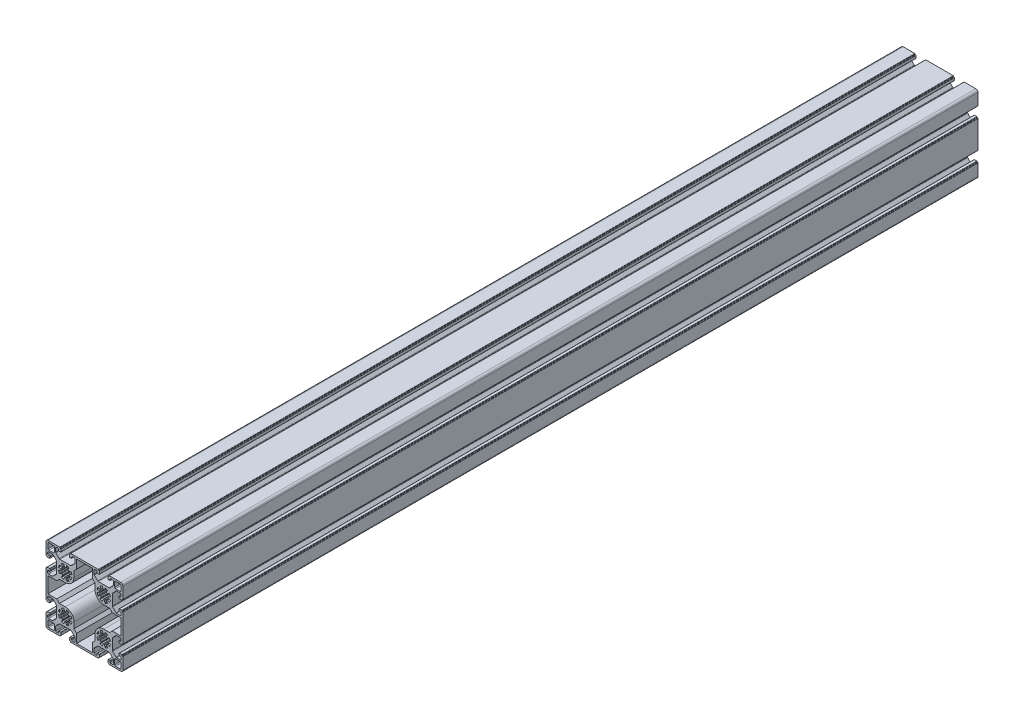
from build123d import *

# Parameters (mm, degrees)
EXTRUDE_1_DEPTH = 1000


with BuildPart() as part:
    # Эскиз1 → Бобышка-Вытянуть1 (new body)
    with BuildSketch(Plane.XY):
        with BuildLine():
            Line((-22.5, 11.25), (-22.5, 20))
            ThreePointArc((-22.5, 20), (-21.767766953, 21.767766953), (-20, 22.5))
            Line((-20, 22.5), (-11.25, 22.5))
            Line((-11.25, 22.5), (-6.4, 22.5))
            ThreePointArc((-6.4, 22.5), (-6.187867966, 22.412132034), (-6.1, 22.2))
            Line((-6.1, 22.2), (-6.1, 21.8))
            ThreePointArc((-6.1, 21.8), (-6.012132034, 21.587867966), (-5.8, 21.5))
            Line((-5.8, 21.5), (-5.4, 21.5))
            ThreePointArc((-5.4, 21.5), (-5.187867966, 21.412132034), (-5.1, 21.2))
            Line((-5.1, 21.2), (-5.1, 18.3))
            ThreePointArc((-5.1, 18.3), (-5.187867966, 18.087867966), (-5.4, 18))
            Line((-5.4, 18), (-7.3, 18))
            ThreePointArc((-7.3, 18), (-7.512132034, 18.087867966), (-7.6, 18.3))
            Line((-7.6, 18.3), (-7.6, 19.5))
            ThreePointArc((-7.6, 19.5), (-7.892893219, 20.207106781), (-8.6, 20.5))
            Line((-8.6, 20.5), (-10.25, 20.5))
            ThreePointArc((-10.25, 20.5), (-10.957106781, 20.207106781), (-11.25, 19.5))
            Line((-11.25, 19.5), (-11.25, 15.114213562))
            ThreePointArc((-11.25, 15.114213562), (-11.173879533, 14.73153013), (-10.957106781, 14.407106781))
            Line((-10.957106781, 14.407106781), (-7.042893219, 10.492893219))
            ThreePointArc((-7.042893219, 10.492893219), (-6.71846987, 10.276120467), (-6.335786438, 10.2))
            Line((-6.335786438, 10.2), (6.335786438, 10.2))
            ThreePointArc((6.335786438, 10.2), (6.71846987, 10.276120467), (7.042893219, 10.492893219))
            Line((7.042893219, 10.492893219), (10.957106781, 14.407106781))
            ThreePointArc((10.957106781, 14.407106781), (11.173879533, 14.73153013), (11.25, 15.114213562))
            Line((11.25, 15.114213562), (11.25, 19.5))
            ThreePointArc((11.25, 19.5), (10.957106781, 20.207106781), (10.25, 20.5))
            Line((10.25, 20.5), (8.6, 20.5))
            ThreePointArc((8.6, 20.5), (7.892893219, 20.207106781), (7.6, 19.5))
            Line((7.6, 19.5), (7.6, 18.3))
            ThreePointArc((7.6, 18.3), (7.512132034, 18.087867966), (7.3, 18))
            Line((7.3, 18), (5.4, 18))
            ThreePointArc((5.4, 18), (5.187867966, 18.087867966), (5.1, 18.3))
            Line((5.1, 18.3), (5.1, 21.2))
            ThreePointArc((5.1, 21.2), (5.187867966, 21.412132034), (5.4, 21.5))
            Line((5.4, 21.5), (5.8, 21.5))
            ThreePointArc((5.8, 21.5), (6.012132034, 21.587867966), (6.1, 21.8))
            Line((6.1, 21.8), (6.1, 22.2))
            ThreePointArc((6.1, 22.2), (6.187867966, 22.412132034), (6.4, 22.5))
            Line((6.4, 22.5), (11.25, 22.5))
            Line((11.25, 22.5), (33.75, 22.5))
            Line((33.75, 22.5), (38.6, 22.5))
            ThreePointArc((38.6, 22.5), (38.812132034, 22.412132034), (38.9, 22.2))
            Line((38.9, 22.2), (38.9, 21.8))
            ThreePointArc((38.9, 21.8), (38.987867966, 21.587867966), (39.2, 21.5))
            Line((39.2, 21.5), (39.6, 21.5))
            ThreePointArc((39.6, 21.5), (39.812132034, 21.412132034), (39.9, 21.2))
            Line((39.9, 21.2), (39.9, 18.3))
            ThreePointArc((39.9, 18.3), (39.812132034, 18.087867966), (39.6, 18))
            Line((39.6, 18), (37.7, 18))
            ThreePointArc((37.7, 18), (37.487867966, 18.087867966), (37.4, 18.3))
            Line((37.4, 18.3), (37.4, 19.5))
            ThreePointArc((37.4, 19.5), (37.107106781, 20.207106781), (36.4, 20.5))
            Line((36.4, 20.5), (34.75, 20.5))
            ThreePointArc((34.75, 20.5), (34.042893219, 20.207106781), (33.75, 19.5))
            Line((33.75, 19.5), (33.75, 15.114213562))
            ThreePointArc((33.75, 15.114213562), (33.826120467, 14.73153013), (34.042893219, 14.407106781))
            Line((34.042893219, 14.407106781), (37.957106781, 10.492893219))
            ThreePointArc((37.957106781, 10.492893219), (38.28153013, 10.276120467), (38.664213562, 10.2))
            Line((38.664213562, 10.2), (51.335786438, 10.2))
            ThreePointArc((51.335786438, 10.2), (51.71846987, 10.276120467), (52.042893219, 10.492893219))
            Line((52.042893219, 10.492893219), (55.957106781, 14.407106781))
            ThreePointArc((55.957106781, 14.407106781), (56.173879533, 14.73153013), (56.25, 15.114213562))
            Line((56.25, 15.114213562), (56.25, 19.5))
            ThreePointArc((56.25, 19.5), (55.957106781, 20.207106781), (55.25, 20.5))
            Line((55.25, 20.5), (53.6, 20.5))
            ThreePointArc((53.6, 20.5), (52.892893219, 20.207106781), (52.6, 19.5))
            Line((52.6, 19.5), (52.6, 18.3))
            ThreePointArc((52.6, 18.3), (52.512132034, 18.087867966), (52.3, 18))
            Line((52.3, 18), (50.4, 18))
            ThreePointArc((50.4, 18), (50.187867966, 18.087867966), (50.1, 18.3))
            Line((50.1, 18.3), (50.1, 21.2))
            ThreePointArc((50.1, 21.2), (50.187867966, 21.412132034), (50.4, 21.5))
            Line((50.4, 21.5), (50.8, 21.5))
            ThreePointArc((50.8, 21.5), (51.012132034, 21.587867966), (51.1, 21.8))
            Line((51.1, 21.8), (51.1, 22.2))
            ThreePointArc((51.1, 22.2), (51.187867966, 22.412132034), (51.4, 22.5))
            Line((51.4, 22.5), (56.25, 22.5))
            Line((56.25, 22.5), (65, 22.5))
            ThreePointArc((65, 22.5), (66.767766953, 21.767766953), (67.5, 20))
            Line((67.5, 20), (67.5, 11.25))
            Line((67.5, 11.25), (67.5, 6.4))
            ThreePointArc((67.5, 6.4), (67.412132034, 6.187867966), (67.2, 6.1))
            Line((67.2, 6.1), (66.8, 6.1))
            ThreePointArc((66.8, 6.1), (66.587867966, 6.012132034), (66.5, 5.8))
            Line((66.5, 5.8), (66.5, 5.4))
            ThreePointArc((66.5, 5.4), (66.412132034, 5.187867966), (66.2, 5.1))
            Line((66.2, 5.1), (63.3, 5.1))
            ThreePointArc((63.3, 5.1), (63.087867966, 5.187867966), (63, 5.4))
            Line((63, 5.4), (63, 7.3))
            ThreePointArc((63, 7.3), (63.087867966, 7.512132034), (63.3, 7.6))
            Line((63.3, 7.6), (64.5, 7.6))
            ThreePointArc((64.5, 7.6), (65.207106781, 7.892893219), (65.5, 8.6))
            Line((65.5, 8.6), (65.5, 10.25))
            ThreePointArc((65.5, 10.25), (65.207106781, 10.957106781), (64.5, 11.25))
            Line((64.5, 11.25), (60.114213562, 11.25))
            ThreePointArc((60.114213562, 11.25), (59.73153013, 11.173879533), (59.407106781, 10.957106781))
            Line((59.407106781, 10.957106781), (55.492893219, 7.042893219))
            ThreePointArc((55.492893219, 7.042893219), (55.276120467, 6.71846987), (55.2, 6.335786438))
            Line((55.2, 6.335786438), (55.2, -6.335786438))
            ThreePointArc((55.2, -6.335786438), (55.276120467, -6.71846987), (55.492893219, -7.042893219))
            Line((55.492893219, -7.042893219), (59.407106781, -10.957106781))
            ThreePointArc((59.407106781, -10.957106781), (59.73153013, -11.173879533), (60.114213562, -11.25))
            Line((60.114213562, -11.25), (64.5, -11.25))
            ThreePointArc((64.5, -11.25), (65.207106781, -10.957106781), (65.5, -10.25))
            Line((65.5, -10.25), (65.5, -8.6))
            ThreePointArc((65.5, -8.6), (65.207106781, -7.892893219), (64.5, -7.6))
            Line((64.5, -7.6), (63.3, -7.6))
            ThreePointArc((63.3, -7.6), (63.087867966, -7.512132034), (63, -7.3))
            Line((63, -7.3), (63, -5.4))
            ThreePointArc((63, -5.4), (63.087867966, -5.187867966), (63.3, -5.1))
            Line((63.3, -5.1), (66.2, -5.1))
            ThreePointArc((66.2, -5.1), (66.412132034, -5.187867966), (66.5, -5.4))
            Line((66.5, -5.4), (66.5, -5.8))
            ThreePointArc((66.5, -5.8), (66.587867966, -6.012132034), (66.8, -6.1))
            Line((66.8, -6.1), (67.2, -6.1))
            ThreePointArc((67.2, -6.1), (67.412132034, -6.187867966), (67.5, -6.4))
            Line((67.5, -6.4), (67.5, -11.25))
            Line((67.5, -11.25), (67.5, -33.75))
            Line((67.5, -33.75), (67.5, -38.6))
            ThreePointArc((67.5, -38.6), (67.412132034, -38.812132034), (67.2, -38.9))
            Line((67.2, -38.9), (66.8, -38.9))
            ThreePointArc((66.8, -38.9), (66.587867966, -38.987867966), (66.5, -39.2))
            Line((66.5, -39.2), (66.5, -39.6))
            ThreePointArc((66.5, -39.6), (66.412132034, -39.812132034), (66.2, -39.9))
            Line((66.2, -39.9), (63.3, -39.9))
            ThreePointArc((63.3, -39.9), (63.087867966, -39.812132034), (63, -39.6))
            Line((63, -39.6), (63, -37.7))
            ThreePointArc((63, -37.7), (63.087867966, -37.487867966), (63.3, -37.4))
            Line((63.3, -37.4), (64.5, -37.4))
            ThreePointArc((64.5, -37.4), (65.207106781, -37.107106781), (65.5, -36.4))
            Line((65.5, -36.4), (65.5, -34.75))
            ThreePointArc((65.5, -34.75), (65.207106781, -34.042893219), (64.5, -33.75))
            Line((64.5, -33.75), (60.114213562, -33.75))
            ThreePointArc((60.114213562, -33.75), (59.73153013, -33.826120467), (59.407106781, -34.042893219))
            Line((59.407106781, -34.042893219), (55.492893219, -37.957106781))
            ThreePointArc((55.492893219, -37.957106781), (55.276120467, -38.28153013), (55.2, -38.664213562))
            Line((55.2, -38.664213562), (55.2, -51.335786438))
            ThreePointArc((55.2, -51.335786438), (55.276120467, -51.71846987), (55.492893219, -52.042893219))
            Line((55.492893219, -52.042893219), (59.407106781, -55.957106781))
            ThreePointArc((59.407106781, -55.957106781), (59.73153013, -56.173879533), (60.114213562, -56.25))
            Line((60.114213562, -56.25), (64.5, -56.25))
            ThreePointArc((64.5, -56.25), (65.207106781, -55.957106781), (65.5, -55.25))
            Line((65.5, -55.25), (65.5, -53.6))
            ThreePointArc((65.5, -53.6), (65.207106781, -52.892893219), (64.5, -52.6))
            Line((64.5, -52.6), (63.3, -52.6))
            ThreePointArc((63.3, -52.6), (63.087867966, -52.512132034), (63, -52.3))
            Line((63, -52.3), (63, -50.4))
            ThreePointArc((63, -50.4), (63.087867966, -50.187867966), (63.3, -50.1))
            Line((63.3, -50.1), (66.2, -50.1))
            ThreePointArc((66.2, -50.1), (66.412132034, -50.187867966), (66.5, -50.4))
            Line((66.5, -50.4), (66.5, -50.8))
            ThreePointArc((66.5, -50.8), (66.587867966, -51.012132034), (66.8, -51.1))
            Line((66.8, -51.1), (67.2, -51.1))
            ThreePointArc((67.2, -51.1), (67.412132034, -51.187867966), (67.5, -51.4))
            Line((67.5, -51.4), (67.5, -56.25))
            Line((67.5, -56.25), (67.5, -65))
            ThreePointArc((67.5, -65), (66.767766953, -66.767766953), (65, -67.5))
            Line((65, -67.5), (56.25, -67.5))
            Line((56.25, -67.5), (51.4, -67.5))
            ThreePointArc((51.4, -67.5), (51.187867966, -67.412132034), (51.1, -67.2))
            Line((51.1, -67.2), (51.1, -66.8))
            ThreePointArc((51.1, -66.8), (51.012132034, -66.587867966), (50.8, -66.5))
            Line((50.8, -66.5), (50.4, -66.5))
            ThreePointArc((50.4, -66.5), (50.187867966, -66.412132034), (50.1, -66.2))
            Line((50.1, -66.2), (50.1, -63.3))
            ThreePointArc((50.1, -63.3), (50.187867966, -63.087867966), (50.4, -63))
            Line((50.4, -63), (52.3, -63))
            ThreePointArc((52.3, -63), (52.512132034, -63.087867966), (52.6, -63.3))
            Line((52.6, -63.3), (52.6, -64.5))
            ThreePointArc((52.6, -64.5), (52.892893219, -65.207106781), (53.6, -65.5))
            Line((53.6, -65.5), (55.25, -65.5))
            ThreePointArc((55.25, -65.5), (55.957106781, -65.207106781), (56.25, -64.5))
            Line((56.25, -64.5), (56.25, -60.114213562))
            ThreePointArc((56.25, -60.114213562), (56.173879533, -59.73153013), (55.957106781, -59.407106781))
            Line((55.957106781, -59.407106781), (52.042893219, -55.492893219))
            ThreePointArc((52.042893219, -55.492893219), (51.71846987, -55.276120467), (51.335786438, -55.2))
            Line((51.335786438, -55.2), (38.664213562, -55.2))
            ThreePointArc((38.664213562, -55.2), (38.28153013, -55.276120467), (37.957106781, -55.492893219))
            Line((37.957106781, -55.492893219), (34.042893219, -59.407106781))
            ThreePointArc((34.042893219, -59.407106781), (33.826120467, -59.73153013), (33.75, -60.114213562))
            Line((33.75, -60.114213562), (33.75, -64.5))
            ThreePointArc((33.75, -64.5), (34.042893219, -65.207106781), (34.75, -65.5))
            Line((34.75, -65.5), (36.4, -65.5))
            ThreePointArc((36.4, -65.5), (37.107106781, -65.207106781), (37.4, -64.5))
            Line((37.4, -64.5), (37.4, -63.3))
            ThreePointArc((37.4, -63.3), (37.487867966, -63.087867966), (37.7, -63))
            Line((37.7, -63), (39.6, -63))
            ThreePointArc((39.6, -63), (39.812132034, -63.087867966), (39.9, -63.3))
            Line((39.9, -63.3), (39.9, -66.2))
            ThreePointArc((39.9, -66.2), (39.812132034, -66.412132034), (39.6, -66.5))
            Line((39.6, -66.5), (39.2, -66.5))
            ThreePointArc((39.2, -66.5), (38.987867966, -66.587867966), (38.9, -66.8))
            Line((38.9, -66.8), (38.9, -67.2))
            ThreePointArc((38.9, -67.2), (38.812132034, -67.412132034), (38.6, -67.5))
            Line((38.6, -67.5), (33.75, -67.5))
            Line((33.75, -67.5), (11.25, -67.5))
            Line((11.25, -67.5), (6.4, -67.5))
            ThreePointArc((6.4, -67.5), (6.187867966, -67.412132034), (6.1, -67.2))
            Line((6.1, -67.2), (6.1, -66.8))
            ThreePointArc((6.1, -66.8), (6.012132034, -66.587867966), (5.8, -66.5))
            Line((5.8, -66.5), (5.4, -66.5))
            ThreePointArc((5.4, -66.5), (5.187867966, -66.412132034), (5.1, -66.2))
            Line((5.1, -66.2), (5.1, -63.3))
            ThreePointArc((5.1, -63.3), (5.187867966, -63.087867966), (5.4, -63))
            Line((5.4, -63), (7.3, -63))
            ThreePointArc((7.3, -63), (7.512132034, -63.087867966), (7.6, -63.3))
            Line((7.6, -63.3), (7.6, -64.5))
            ThreePointArc((7.6, -64.5), (7.892893219, -65.207106781), (8.6, -65.5))
            Line((8.6, -65.5), (10.25, -65.5))
            ThreePointArc((10.25, -65.5), (10.957106781, -65.207106781), (11.25, -64.5))
            Line((11.25, -64.5), (11.25, -60.114213562))
            ThreePointArc((11.25, -60.114213562), (11.173879533, -59.73153013), (10.957106781, -59.407106781))
            Line((10.957106781, -59.407106781), (7.042893219, -55.492893219))
            ThreePointArc((7.042893219, -55.492893219), (6.71846987, -55.276120467), (6.335786438, -55.2))
            Line((6.335786438, -55.2), (-6.335786438, -55.2))
            ThreePointArc((-6.335786438, -55.2), (-6.71846987, -55.276120467), (-7.042893219, -55.492893219))
            Line((-7.042893219, -55.492893219), (-10.957106781, -59.407106781))
            ThreePointArc((-10.957106781, -59.407106781), (-11.173879533, -59.73153013), (-11.25, -60.114213562))
            Line((-11.25, -60.114213562), (-11.25, -64.5))
            ThreePointArc((-11.25, -64.5), (-10.957106781, -65.207106781), (-10.25, -65.5))
            Line((-10.25, -65.5), (-8.6, -65.5))
            ThreePointArc((-8.6, -65.5), (-7.892893219, -65.207106781), (-7.6, -64.5))
            Line((-7.6, -64.5), (-7.6, -63.3))
            ThreePointArc((-7.6, -63.3), (-7.512132034, -63.087867966), (-7.3, -63))
            Line((-7.3, -63), (-5.4, -63))
            ThreePointArc((-5.4, -63), (-5.187867966, -63.087867966), (-5.1, -63.3))
            Line((-5.1, -63.3), (-5.1, -66.2))
            ThreePointArc((-5.1, -66.2), (-5.187867966, -66.412132034), (-5.4, -66.5))
            Line((-5.4, -66.5), (-5.8, -66.5))
            ThreePointArc((-5.8, -66.5), (-6.012132034, -66.587867966), (-6.1, -66.8))
            Line((-6.1, -66.8), (-6.1, -67.2))
            ThreePointArc((-6.1, -67.2), (-6.187867966, -67.412132034), (-6.4, -67.5))
            Line((-6.4, -67.5), (-11.25, -67.5))
            Line((-11.25, -67.5), (-20, -67.5))
            ThreePointArc((-20, -67.5), (-21.767766953, -66.767766953), (-22.5, -65))
            Line((-22.5, -65), (-22.5, -56.25))
            Line((-22.5, -56.25), (-22.5, -51.4))
            ThreePointArc((-22.5, -51.4), (-22.412132034, -51.187867966), (-22.2, -51.1))
            Line((-22.2, -51.1), (-21.8, -51.1))
            ThreePointArc((-21.8, -51.1), (-21.587867966, -51.012132034), (-21.5, -50.8))
            Line((-21.5, -50.8), (-21.5, -50.4))
            ThreePointArc((-21.5, -50.4), (-21.412132034, -50.187867966), (-21.2, -50.1))
            Line((-21.2, -50.1), (-18.3, -50.1))
            ThreePointArc((-18.3, -50.1), (-18.087867966, -50.187867966), (-18, -50.4))
            Line((-18, -50.4), (-18, -52.3))
            ThreePointArc((-18, -52.3), (-18.087867966, -52.512132034), (-18.3, -52.6))
            Line((-18.3, -52.6), (-19.5, -52.6))
            ThreePointArc((-19.5, -52.6), (-20.207106781, -52.892893219), (-20.5, -53.6))
            Line((-20.5, -53.6), (-20.5, -55.25))
            ThreePointArc((-20.5, -55.25), (-20.207106781, -55.957106781), (-19.5, -56.25))
            Line((-19.5, -56.25), (-15.114213562, -56.25))
            ThreePointArc((-15.114213562, -56.25), (-14.73153013, -56.173879533), (-14.407106781, -55.957106781))
            Line((-14.407106781, -55.957106781), (-10.492893219, -52.042893219))
            ThreePointArc((-10.492893219, -52.042893219), (-10.276120467, -51.71846987), (-10.2, -51.335786438))
            Line((-10.2, -51.335786438), (-10.2, -38.664213562))
            ThreePointArc((-10.2, -38.664213562), (-10.276120467, -38.28153013), (-10.492893219, -37.957106781))
            Line((-10.492893219, -37.957106781), (-14.407106781, -34.042893219))
            ThreePointArc((-14.407106781, -34.042893219), (-14.73153013, -33.826120467), (-15.114213562, -33.75))
            Line((-15.114213562, -33.75), (-19.5, -33.75))
            ThreePointArc((-19.5, -33.75), (-20.207106781, -34.042893219), (-20.5, -34.75))
            Line((-20.5, -34.75), (-20.5, -36.4))
            ThreePointArc((-20.5, -36.4), (-20.207106781, -37.107106781), (-19.5, -37.4))
            Line((-19.5, -37.4), (-18.3, -37.4))
            ThreePointArc((-18.3, -37.4), (-18.087867966, -37.487867966), (-18, -37.7))
            Line((-18, -37.7), (-18, -39.6))
            ThreePointArc((-18, -39.6), (-18.087867966, -39.812132034), (-18.3, -39.9))
            Line((-18.3, -39.9), (-21.2, -39.9))
            ThreePointArc((-21.2, -39.9), (-21.412132034, -39.812132034), (-21.5, -39.6))
            Line((-21.5, -39.6), (-21.5, -39.2))
            ThreePointArc((-21.5, -39.2), (-21.587867966, -38.987867966), (-21.8, -38.9))
            Line((-21.8, -38.9), (-22.2, -38.9))
            ThreePointArc((-22.2, -38.9), (-22.412132034, -38.812132034), (-22.5, -38.6))
            Line((-22.5, -38.6), (-22.5, -33.75))
            Line((-22.5, -33.75), (-22.5, -11.25))
            Line((-22.5, -11.25), (-22.5, -6.4))
            ThreePointArc((-22.5, -6.4), (-22.412132034, -6.187867966), (-22.2, -6.1))
            Line((-22.2, -6.1), (-21.8, -6.1))
            ThreePointArc((-21.8, -6.1), (-21.587867966, -6.012132034), (-21.5, -5.8))
            Line((-21.5, -5.8), (-21.5, -5.4))
            ThreePointArc((-21.5, -5.4), (-21.412132034, -5.187867966), (-21.2, -5.1))
            Line((-21.2, -5.1), (-18.3, -5.1))
            ThreePointArc((-18.3, -5.1), (-18.087867966, -5.187867966), (-18, -5.4))
            Line((-18, -5.4), (-18, -7.3))
            ThreePointArc((-18, -7.3), (-18.087867966, -7.512132034), (-18.3, -7.6))
            Line((-18.3, -7.6), (-19.5, -7.6))
            ThreePointArc((-19.5, -7.6), (-20.207106781, -7.892893219), (-20.5, -8.6))
            Line((-20.5, -8.6), (-20.5, -10.25))
            ThreePointArc((-20.5, -10.25), (-20.207106781, -10.957106781), (-19.5, -11.25))
            Line((-19.5, -11.25), (-15.114213562, -11.25))
            ThreePointArc((-15.114213562, -11.25), (-14.73153013, -11.173879533), (-14.407106781, -10.957106781))
            Line((-14.407106781, -10.957106781), (-10.492893219, -7.042893219))
            ThreePointArc((-10.492893219, -7.042893219), (-10.276120467, -6.71846987), (-10.2, -6.335786438))
            Line((-10.2, -6.335786438), (-10.2, 6.335786438))
            ThreePointArc((-10.2, 6.335786438), (-10.276120467, 6.71846987), (-10.492893219, 7.042893219))
            Line((-10.492893219, 7.042893219), (-14.407106781, 10.957106781))
            ThreePointArc((-14.407106781, 10.957106781), (-14.73153013, 11.173879533), (-15.114213562, 11.25))
            Line((-15.114213562, 11.25), (-19.5, 11.25))
            ThreePointArc((-19.5, 11.25), (-20.207106781, 10.957106781), (-20.5, 10.25))
            Line((-20.5, 10.25), (-20.5, 8.6))
            ThreePointArc((-20.5, 8.6), (-20.207106781, 7.892893219), (-19.5, 7.6))
            Line((-19.5, 7.6), (-18.3, 7.6))
            ThreePointArc((-18.3, 7.6), (-18.087867966, 7.512132034), (-18, 7.3))
            Line((-18, 7.3), (-18, 5.4))
            ThreePointArc((-18, 5.4), (-18.087867966, 5.187867966), (-18.3, 5.1))
            Line((-18.3, 5.1), (-21.2, 5.1))
            ThreePointArc((-21.2, 5.1), (-21.412132034, 5.187867966), (-21.5, 5.4))
            Line((-21.5, 5.4), (-21.5, 5.8))
            ThreePointArc((-21.5, 5.8), (-21.587867966, 6.012132034), (-21.8, 6.1))
            Line((-21.8, 6.1), (-22.2, 6.1))
            ThreePointArc((-22.2, 6.1), (-22.412132034, 6.187867966), (-22.5, 6.4))
            Line((-22.5, 6.4), (-22.5, 11.25))
        make_face()
        with BuildLine():
            Line((65.3, 14), (65.3, 19.5))
            ThreePointArc((65.3, 19.5), (65.007106781, 20.207106781), (64.3, 20.5))
            Line((64.3, 20.5), (58.8, 20.5))
            ThreePointArc((58.8, 20.5), (58.092893219, 20.207106781), (57.8, 19.5))
            Line((57.8, 19.5), (57.8, 14))
            ThreePointArc((57.8, 14), (58.092893219, 13.292893219), (58.8, 13))
            Line((58.8, 13), (64.3, 13))
            ThreePointArc((64.3, 13), (65.007106781, 13.292893219), (65.3, 14))
        make_face(mode=Mode.SUBTRACT)
        with BuildLine():
            Line((-13.8, 13), (-19.3, 13))
            ThreePointArc((-19.3, 13), (-20.007106781, 13.292893219), (-20.3, 14))
            Line((-20.3, 14), (-20.3, 19.5))
            ThreePointArc((-20.3, 19.5), (-20.007106781, 20.207106781), (-19.3, 20.5))
            Line((-19.3, 20.5), (-13.8, 20.5))
            ThreePointArc((-13.8, 20.5), (-13.092893219, 20.207106781), (-12.8, 19.5))
            Line((-12.8, 19.5), (-12.8, 14))
            ThreePointArc((-12.8, 14), (-13.092893219, 13.292893219), (-13.8, 13))
        make_face(mode=Mode.SUBTRACT)
        with BuildLine():
            Line((58.8, -58), (64.3, -58))
            ThreePointArc((64.3, -58), (65.007106781, -58.292893219), (65.3, -59))
            Line((65.3, -59), (65.3, -64.5))
            ThreePointArc((65.3, -64.5), (65.007106781, -65.207106781), (64.3, -65.5))
            Line((64.3, -65.5), (58.8, -65.5))
            ThreePointArc((58.8, -65.5), (58.092893219, -65.207106781), (57.8, -64.5))
            Line((57.8, -64.5), (57.8, -59))
            ThreePointArc((57.8, -59), (58.092893219, -58.292893219), (58.8, -58))
        make_face(mode=Mode.SUBTRACT)
        with BuildLine():
            Line((-20.3, -59), (-20.3, -64.5))
            ThreePointArc((-20.3, -64.5), (-20.007106781, -65.207106781), (-19.3, -65.5))
            Line((-19.3, -65.5), (-13.8, -65.5))
            ThreePointArc((-13.8, -65.5), (-13.092893219, -65.207106781), (-12.8, -64.5))
            Line((-12.8, -64.5), (-12.8, -59))
            ThreePointArc((-12.8, -59), (-13.092893219, -58.292893219), (-13.8, -58))
            Line((-13.8, -58), (-19.3, -58))
            ThreePointArc((-19.3, -58), (-20.007106781, -58.292893219), (-20.3, -59))
        make_face(mode=Mode.SUBTRACT)
        with BuildLine():
            Line((-20.3, -31.75), (-20.3, -13.25))
            Line((-20.3, -13.25), (-9.911774901, -13.25))
            Line((-9.911774901, -13.25), (-6.861774901, -10.2))
            Line((-6.861774901, -10.2), (0, -10.2))
            ThreePointArc((0, -10.2), (7.212489168, -7.212489168), (10.2, 0))
            Line((10.2, 0), (10.2, 6.861774901))
            Line((10.2, 6.861774901), (13.25, 9.911774901))
            Line((13.25, 9.911774901), (13.25, 20.3))
            Line((13.25, 20.3), (31.75, 20.3))
            Line((31.75, 20.3), (31.75, 9.911774901))
            Line((31.75, 9.911774901), (34.8, 6.861774901))
            Line((34.8, 6.861774901), (34.8, 0))
            ThreePointArc((34.8, 0), (37.787510832, -7.212489168), (45, -10.2))
            Line((45, -10.2), (51.861774901, -10.2))
            Line((51.861774901, -10.2), (54.911774901, -13.25))
            Line((54.911774901, -13.25), (65.3, -13.25))
            Line((65.3, -13.25), (65.3, -31.75))
            Line((65.3, -31.75), (54.911774901, -31.75))
            Line((54.911774901, -31.75), (51.861774901, -34.8))
            Line((51.861774901, -34.8), (45, -34.8))
            ThreePointArc((45, -34.8), (37.787510832, -37.787510832), (34.8, -45))
            Line((34.8, -45), (34.8, -51.861774901))
            Line((34.8, -51.861774901), (31.75, -54.911774901))
            Line((31.75, -54.911774901), (31.75, -65.3))
            Line((31.75, -65.3), (13.25, -65.3))
            Line((13.25, -65.3), (13.25, -54.911774901))
            Line((13.25, -54.911774901), (10.2, -51.861774901))
            Line((10.2, -51.861774901), (10.2, -45))
            ThreePointArc((10.2, -45), (7.212489168, -37.787510832), (0, -34.8))
            Line((0, -34.8), (-6.861774901, -34.8))
            Line((-6.861774901, -34.8), (-9.911774901, -31.75))
            Line((-9.911774901, -31.75), (-20.3, -31.75))
        make_face(mode=Mode.SUBTRACT)
        with BuildLine():
            Line((1.3637258, 7.358005976), (1.016443046, 5.484235912))
            ThreePointArc((1.016443046, 5.484235912), (0.826149864, 5.176357864), (0.477957057, 5.077554239))
            ThreePointArc((0.477957057, 5.077554239), (0, 5.1), (-0.477957057, 5.077554239))
            ThreePointArc((-0.477957057, 5.077554239), (-0.826149864, 5.176357864), (-1.016443046, 5.484235912))
            Line((-1.016443046, 5.484235912), (-1.3637258, 7.358005976))
            ThreePointArc((-1.3637258, 7.358005976), (-1.586050772, 7.688167424), (-1.979043471, 7.751347427))
            ThreePointArc((-1.979043471, 7.751347427), (-3.061467459, 7.39103626), (-4.081635271, 6.880425388))
            ThreePointArc((-4.081635271, 6.880425388), (-4.314848064, 6.557862576), (-4.238596161, 6.167195683))
            Line((-4.238596161, 6.167195683), (-3.159206632, 4.596674173))
            ThreePointArc((-3.159206632, 4.596674173), (-3.076061576, 4.244413919), (-3.252406358, 3.928339711))
            ThreePointArc((-3.252406358, 3.928339711), (-3.606244584, 3.606244584), (-3.928339711, 3.252406358))
            ThreePointArc((-3.928339711, 3.252406358), (-4.244413919, 3.076061576), (-4.596674173, 3.159206632))
            Line((-4.596674173, 3.159206632), (-6.167195683, 4.238596161))
            ThreePointArc((-6.167195683, 4.238596161), (-6.557862576, 4.314848064), (-6.880425388, 4.081635271))
            ThreePointArc((-6.880425388, 4.081635271), (-7.39103626, 3.061467459), (-7.751347427, 1.979043471))
            ThreePointArc((-7.751347427, 1.979043471), (-7.688167424, 1.586050772), (-7.358005976, 1.3637258))
            Line((-7.358005976, 1.3637258), (-5.484235912, 1.016443046))
            ThreePointArc((-5.484235912, 1.016443046), (-5.176357864, 0.826149864), (-5.077554239, 0.477957057))
            ThreePointArc((-5.077554239, 0.477957057), (-5.1, 0), (-5.077554239, -0.477957057))
            ThreePointArc((-5.077554239, -0.477957057), (-5.176357864, -0.826149864), (-5.484235912, -1.016443046))
            Line((-5.484235912, -1.016443046), (-7.358005976, -1.3637258))
            ThreePointArc((-7.358005976, -1.3637258), (-7.688167424, -1.586050772), (-7.751347427, -1.979043471))
            ThreePointArc((-7.751347427, -1.979043471), (-7.39103626, -3.061467459), (-6.880425388, -4.081635271))
            ThreePointArc((-6.880425388, -4.081635271), (-6.557862576, -4.314848064), (-6.167195683, -4.238596161))
            Line((-6.167195683, -4.238596161), (-4.596674173, -3.159206632))
            ThreePointArc((-4.596674173, -3.159206632), (-4.244413919, -3.076061576), (-3.928339711, -3.252406358))
            ThreePointArc((-3.928339711, -3.252406358), (-3.606244584, -3.606244584), (-3.252406358, -3.928339711))
            ThreePointArc((-3.252406358, -3.928339711), (-3.076061576, -4.244413919), (-3.159206632, -4.596674173))
            Line((-3.159206632, -4.596674173), (-4.238596161, -6.167195683))
            ThreePointArc((-4.238596161, -6.167195683), (-4.314848064, -6.557862576), (-4.081635271, -6.880425388))
            ThreePointArc((-4.081635271, -6.880425388), (-3.061467459, -7.39103626), (-1.979043471, -7.751347427))
            ThreePointArc((-1.979043471, -7.751347427), (-1.586050772, -7.688167424), (-1.3637258, -7.358005976))
            Line((-1.3637258, -7.358005976), (-1.016443046, -5.484235912))
            ThreePointArc((-1.016443046, -5.484235912), (-0.826149864, -5.176357864), (-0.477957057, -5.077554239))
            ThreePointArc((-0.477957057, -5.077554239), (0, -5.1), (0.477957057, -5.077554239))
            ThreePointArc((0.477957057, -5.077554239), (0.826149864, -5.176357864), (1.016443046, -5.484235912))
            Line((1.016443046, -5.484235912), (1.3637258, -7.358005976))
            ThreePointArc((1.3637258, -7.358005976), (1.586050772, -7.688167424), (1.979043471, -7.751347427))
            ThreePointArc((1.979043471, -7.751347427), (3.061467459, -7.39103626), (4.081635271, -6.880425388))
            ThreePointArc((4.081635271, -6.880425388), (4.314848064, -6.557862576), (4.238596161, -6.167195683))
            Line((4.238596161, -6.167195683), (3.159206632, -4.596674173))
            ThreePointArc((3.159206632, -4.596674173), (3.076061576, -4.244413919), (3.252406358, -3.928339711))
            ThreePointArc((3.252406358, -3.928339711), (3.606244584, -3.606244584), (3.928339711, -3.252406358))
            ThreePointArc((3.928339711, -3.252406358), (4.244413919, -3.076061576), (4.596674173, -3.159206632))
            Line((4.596674173, -3.159206632), (6.167195683, -4.238596161))
            ThreePointArc((6.167195683, -4.238596161), (6.557862576, -4.314848064), (6.880425388, -4.081635271))
            ThreePointArc((6.880425388, -4.081635271), (7.39103626, -3.061467459), (7.751347427, -1.979043471))
            ThreePointArc((7.751347427, -1.979043471), (7.688167424, -1.586050772), (7.358005976, -1.3637258))
            Line((7.358005976, -1.3637258), (5.484235912, -1.016443046))
            ThreePointArc((5.484235912, -1.016443046), (5.176357864, -0.826149864), (5.077554239, -0.477957057))
            ThreePointArc((5.077554239, -0.477957057), (5.1, 0), (5.077554239, 0.477957057))
            ThreePointArc((5.077554239, 0.477957057), (5.176357864, 0.826149864), (5.484235912, 1.016443046))
            Line((5.484235912, 1.016443046), (7.358005976, 1.3637258))
            ThreePointArc((7.358005976, 1.3637258), (7.688167424, 1.586050772), (7.751347427, 1.979043471))
            ThreePointArc((7.751347427, 1.979043471), (7.39103626, 3.061467459), (6.880425388, 4.081635271))
            ThreePointArc((6.880425388, 4.081635271), (6.557862576, 4.314848064), (6.167195683, 4.238596161))
            Line((6.167195683, 4.238596161), (4.596674173, 3.159206632))
            ThreePointArc((4.596674173, 3.159206632), (4.244413919, 3.076061576), (3.928339711, 3.252406358))
            ThreePointArc((3.928339711, 3.252406358), (3.606244584, 3.606244584), (3.252406358, 3.928339711))
            ThreePointArc((3.252406358, 3.928339711), (3.076061576, 4.244413919), (3.159206632, 4.596674173))
            Line((3.159206632, 4.596674173), (4.238596161, 6.167195683))
            ThreePointArc((4.238596161, 6.167195683), (4.314848064, 6.557862576), (4.081635271, 6.880425388))
            ThreePointArc((4.081635271, 6.880425388), (3.061467459, 7.39103626), (1.979043471, 7.751347427))
            ThreePointArc((1.979043471, 7.751347427), (1.586050772, 7.688167424), (1.3637258, 7.358005976))
        make_face(mode=Mode.SUBTRACT)
        with BuildLine():
            Line((43.6362742, 7.358005976), (43.983556954, 5.484235912))
            ThreePointArc((43.983556954, 5.484235912), (44.173850136, 5.176357864), (44.522042943, 5.077554239))
            ThreePointArc((44.522042943, 5.077554239), (45, 5.1), (45.477957057, 5.077554239))
            ThreePointArc((45.477957057, 5.077554239), (45.826149864, 5.176357864), (46.016443046, 5.484235912))
            Line((46.016443046, 5.484235912), (46.3637258, 7.358005976))
            ThreePointArc((46.3637258, 7.358005976), (46.586050772, 7.688167424), (46.979043471, 7.751347427))
            ThreePointArc((46.979043471, 7.751347427), (48.061467459, 7.39103626), (49.081635271, 6.880425388))
            ThreePointArc((49.081635271, 6.880425388), (49.314848064, 6.557862576), (49.238596161, 6.167195683))
            Line((49.238596161, 6.167195683), (48.159206632, 4.596674173))
            ThreePointArc((48.159206632, 4.596674173), (48.076061576, 4.244413919), (48.252406358, 3.928339711))
            ThreePointArc((48.252406358, 3.928339711), (48.606244584, 3.606244584), (48.928339711, 3.252406358))
            ThreePointArc((48.928339711, 3.252406358), (49.244413919, 3.076061576), (49.596674173, 3.159206632))
            Line((49.596674173, 3.159206632), (51.167195683, 4.238596161))
            ThreePointArc((51.167195683, 4.238596161), (51.557862576, 4.314848064), (51.880425388, 4.081635271))
            ThreePointArc((51.880425388, 4.081635271), (52.39103626, 3.061467459), (52.751347427, 1.979043471))
            ThreePointArc((52.751347427, 1.979043471), (52.688167424, 1.586050772), (52.358005976, 1.3637258))
            Line((52.358005976, 1.3637258), (50.484235912, 1.016443046))
            ThreePointArc((50.484235912, 1.016443046), (50.176357864, 0.826149864), (50.077554239, 0.477957057))
            ThreePointArc((50.077554239, 0.477957057), (50.1, 0), (50.077554239, -0.477957057))
            ThreePointArc((50.077554239, -0.477957057), (50.176357864, -0.826149864), (50.484235912, -1.016443046))
            Line((50.484235912, -1.016443046), (52.358005976, -1.3637258))
            ThreePointArc((52.358005976, -1.3637258), (52.688167424, -1.586050772), (52.751347427, -1.979043471))
            ThreePointArc((52.751347427, -1.979043471), (52.39103626, -3.061467459), (51.880425388, -4.081635271))
            ThreePointArc((51.880425388, -4.081635271), (51.557862576, -4.314848064), (51.167195683, -4.238596161))
            Line((51.167195683, -4.238596161), (49.596674173, -3.159206632))
            ThreePointArc((49.596674173, -3.159206632), (49.244413919, -3.076061576), (48.928339711, -3.252406358))
            ThreePointArc((48.928339711, -3.252406358), (48.606244584, -3.606244584), (48.252406358, -3.928339711))
            ThreePointArc((48.252406358, -3.928339711), (48.076061576, -4.244413919), (48.159206632, -4.596674173))
            Line((48.159206632, -4.596674173), (49.238596161, -6.167195683))
            ThreePointArc((49.238596161, -6.167195683), (49.314848064, -6.557862576), (49.081635271, -6.880425388))
            ThreePointArc((49.081635271, -6.880425388), (48.061467459, -7.39103626), (46.979043471, -7.751347427))
            ThreePointArc((46.979043471, -7.751347427), (46.586050772, -7.688167424), (46.3637258, -7.358005976))
            Line((46.3637258, -7.358005976), (46.016443046, -5.484235912))
            ThreePointArc((46.016443046, -5.484235912), (45.826149864, -5.176357864), (45.477957057, -5.077554239))
            ThreePointArc((45.477957057, -5.077554239), (45, -5.1), (44.522042943, -5.077554239))
            ThreePointArc((44.522042943, -5.077554239), (44.173850136, -5.176357864), (43.983556954, -5.484235912))
            Line((43.983556954, -5.484235912), (43.6362742, -7.358005976))
            ThreePointArc((43.6362742, -7.358005976), (43.413949228, -7.688167424), (43.020956529, -7.751347427))
            ThreePointArc((43.020956529, -7.751347427), (41.938532541, -7.39103626), (40.918364729, -6.880425388))
            ThreePointArc((40.918364729, -6.880425388), (40.685151936, -6.557862576), (40.761403839, -6.167195683))
            Line((40.761403839, -6.167195683), (41.840793368, -4.596674173))
            ThreePointArc((41.840793368, -4.596674173), (41.923938424, -4.244413919), (41.747593642, -3.928339711))
            ThreePointArc((41.747593642, -3.928339711), (41.393755416, -3.606244584), (41.071660289, -3.252406358))
            ThreePointArc((41.071660289, -3.252406358), (40.755586081, -3.076061576), (40.403325827, -3.159206632))
            Line((40.403325827, -3.159206632), (38.832804317, -4.238596161))
            ThreePointArc((38.832804317, -4.238596161), (38.442137424, -4.314848064), (38.119574612, -4.081635271))
            ThreePointArc((38.119574612, -4.081635271), (37.60896374, -3.061467459), (37.248652573, -1.979043471))
            ThreePointArc((37.248652573, -1.979043471), (37.311832576, -1.586050772), (37.641994024, -1.3637258))
            Line((37.641994024, -1.3637258), (39.515764088, -1.016443046))
            ThreePointArc((39.515764088, -1.016443046), (39.823642136, -0.826149864), (39.922445761, -0.477957057))
            ThreePointArc((39.922445761, -0.477957057), (39.9, 0), (39.922445761, 0.477957057))
            ThreePointArc((39.922445761, 0.477957057), (39.823642136, 0.826149864), (39.515764088, 1.016443046))
            Line((39.515764088, 1.016443046), (37.641994024, 1.3637258))
            ThreePointArc((37.641994024, 1.3637258), (37.311832576, 1.586050772), (37.248652573, 1.979043471))
            ThreePointArc((37.248652573, 1.979043471), (37.60896374, 3.061467459), (38.119574612, 4.081635271))
            ThreePointArc((38.119574612, 4.081635271), (38.442137424, 4.314848064), (38.832804317, 4.238596161))
            Line((38.832804317, 4.238596161), (40.403325827, 3.159206632))
            ThreePointArc((40.403325827, 3.159206632), (40.755586081, 3.076061576), (41.071660289, 3.252406358))
            ThreePointArc((41.071660289, 3.252406358), (41.393755416, 3.606244584), (41.747593642, 3.928339711))
            ThreePointArc((41.747593642, 3.928339711), (41.923938424, 4.244413919), (41.840793368, 4.596674173))
            Line((41.840793368, 4.596674173), (40.761403839, 6.167195683))
            ThreePointArc((40.761403839, 6.167195683), (40.685151936, 6.557862576), (40.918364729, 6.880425388))
            ThreePointArc((40.918364729, 6.880425388), (41.938532541, 7.39103626), (43.020956529, 7.751347427))
            ThreePointArc((43.020956529, 7.751347427), (43.413949228, 7.688167424), (43.6362742, 7.358005976))
        make_face(mode=Mode.SUBTRACT)
        with BuildLine():
            Line((1.3637258, -52.358005976), (1.016443046, -50.484235912))
            ThreePointArc((1.016443046, -50.484235912), (0.826149864, -50.176357864), (0.477957057, -50.077554239))
            ThreePointArc((0.477957057, -50.077554239), (0, -50.1), (-0.477957057, -50.077554239))
            ThreePointArc((-0.477957057, -50.077554239), (-0.826149864, -50.176357864), (-1.016443046, -50.484235912))
            Line((-1.016443046, -50.484235912), (-1.3637258, -52.358005976))
            ThreePointArc((-1.3637258, -52.358005976), (-1.586050772, -52.688167424), (-1.979043471, -52.751347427))
            ThreePointArc((-1.979043471, -52.751347427), (-3.061467459, -52.39103626), (-4.081635271, -51.880425388))
            ThreePointArc((-4.081635271, -51.880425388), (-4.314848064, -51.557862576), (-4.238596161, -51.167195683))
            Line((-4.238596161, -51.167195683), (-3.159206632, -49.596674173))
            ThreePointArc((-3.159206632, -49.596674173), (-3.076061576, -49.244413919), (-3.252406358, -48.928339711))
            ThreePointArc((-3.252406358, -48.928339711), (-3.606244584, -48.606244584), (-3.928339711, -48.252406358))
            ThreePointArc((-3.928339711, -48.252406358), (-4.244413919, -48.076061576), (-4.596674173, -48.159206632))
            Line((-4.596674173, -48.159206632), (-6.167195683, -49.238596161))
            ThreePointArc((-6.167195683, -49.238596161), (-6.557862576, -49.314848064), (-6.880425388, -49.081635271))
            ThreePointArc((-6.880425388, -49.081635271), (-7.39103626, -48.061467459), (-7.751347427, -46.979043471))
            ThreePointArc((-7.751347427, -46.979043471), (-7.688167424, -46.586050772), (-7.358005976, -46.3637258))
            Line((-7.358005976, -46.3637258), (-5.484235912, -46.016443046))
            ThreePointArc((-5.484235912, -46.016443046), (-5.176357864, -45.826149864), (-5.077554239, -45.477957057))
            ThreePointArc((-5.077554239, -45.477957057), (-5.1, -45), (-5.077554239, -44.522042943))
            ThreePointArc((-5.077554239, -44.522042943), (-5.176357864, -44.173850136), (-5.484235912, -43.983556954))
            Line((-5.484235912, -43.983556954), (-7.358005976, -43.6362742))
            ThreePointArc((-7.358005976, -43.6362742), (-7.688167424, -43.413949228), (-7.751347427, -43.020956529))
            ThreePointArc((-7.751347427, -43.020956529), (-7.39103626, -41.938532541), (-6.880425388, -40.918364729))
            ThreePointArc((-6.880425388, -40.918364729), (-6.557862576, -40.685151936), (-6.167195683, -40.761403839))
            Line((-6.167195683, -40.761403839), (-4.596674173, -41.840793368))
            ThreePointArc((-4.596674173, -41.840793368), (-4.244413919, -41.923938424), (-3.928339711, -41.747593642))
            ThreePointArc((-3.928339711, -41.747593642), (-3.606244584, -41.393755416), (-3.252406358, -41.071660289))
            ThreePointArc((-3.252406358, -41.071660289), (-3.076061576, -40.755586081), (-3.159206632, -40.403325827))
            Line((-3.159206632, -40.403325827), (-4.238596161, -38.832804317))
            ThreePointArc((-4.238596161, -38.832804317), (-4.314848064, -38.442137424), (-4.081635271, -38.119574612))
            ThreePointArc((-4.081635271, -38.119574612), (-3.061467459, -37.60896374), (-1.979043471, -37.248652573))
            ThreePointArc((-1.979043471, -37.248652573), (-1.586050772, -37.311832576), (-1.3637258, -37.641994024))
            Line((-1.3637258, -37.641994024), (-1.016443046, -39.515764088))
            ThreePointArc((-1.016443046, -39.515764088), (-0.826149864, -39.823642136), (-0.477957057, -39.922445761))
            ThreePointArc((-0.477957057, -39.922445761), (0, -39.9), (0.477957057, -39.922445761))
            ThreePointArc((0.477957057, -39.922445761), (0.826149864, -39.823642136), (1.016443046, -39.515764088))
            Line((1.016443046, -39.515764088), (1.3637258, -37.641994024))
            ThreePointArc((1.3637258, -37.641994024), (1.586050772, -37.311832576), (1.979043471, -37.248652573))
            ThreePointArc((1.979043471, -37.248652573), (3.061467459, -37.60896374), (4.081635271, -38.119574612))
            ThreePointArc((4.081635271, -38.119574612), (4.314848064, -38.442137424), (4.238596161, -38.832804317))
            Line((4.238596161, -38.832804317), (3.159206632, -40.403325827))
            ThreePointArc((3.159206632, -40.403325827), (3.076061576, -40.755586081), (3.252406358, -41.071660289))
            ThreePointArc((3.252406358, -41.071660289), (3.606244584, -41.393755416), (3.928339711, -41.747593642))
            ThreePointArc((3.928339711, -41.747593642), (4.244413919, -41.923938424), (4.596674173, -41.840793368))
            Line((4.596674173, -41.840793368), (6.167195683, -40.761403839))
            ThreePointArc((6.167195683, -40.761403839), (6.557862576, -40.685151936), (6.880425388, -40.918364729))
            ThreePointArc((6.880425388, -40.918364729), (7.39103626, -41.938532541), (7.751347427, -43.020956529))
            ThreePointArc((7.751347427, -43.020956529), (7.688167424, -43.413949228), (7.358005976, -43.6362742))
            Line((7.358005976, -43.6362742), (5.484235912, -43.983556954))
            ThreePointArc((5.484235912, -43.983556954), (5.176357864, -44.173850136), (5.077554239, -44.522042943))
            ThreePointArc((5.077554239, -44.522042943), (5.1, -45), (5.077554239, -45.477957057))
            ThreePointArc((5.077554239, -45.477957057), (5.176357864, -45.826149864), (5.484235912, -46.016443046))
            Line((5.484235912, -46.016443046), (7.358005976, -46.3637258))
            ThreePointArc((7.358005976, -46.3637258), (7.688167424, -46.586050772), (7.751347427, -46.979043471))
            ThreePointArc((7.751347427, -46.979043471), (7.39103626, -48.061467459), (6.880425388, -49.081635271))
            ThreePointArc((6.880425388, -49.081635271), (6.557862576, -49.314848064), (6.167195683, -49.238596161))
            Line((6.167195683, -49.238596161), (4.596674173, -48.159206632))
            ThreePointArc((4.596674173, -48.159206632), (4.244413919, -48.076061576), (3.928339711, -48.252406358))
            ThreePointArc((3.928339711, -48.252406358), (3.606244584, -48.606244584), (3.252406358, -48.928339711))
            ThreePointArc((3.252406358, -48.928339711), (3.076061576, -49.244413919), (3.159206632, -49.596674173))
            Line((3.159206632, -49.596674173), (4.238596161, -51.167195683))
            ThreePointArc((4.238596161, -51.167195683), (4.314848064, -51.557862576), (4.081635271, -51.880425388))
            ThreePointArc((4.081635271, -51.880425388), (3.061467459, -52.39103626), (1.979043471, -52.751347427))
            ThreePointArc((1.979043471, -52.751347427), (1.586050772, -52.688167424), (1.3637258, -52.358005976))
        make_face(mode=Mode.SUBTRACT)
        with BuildLine():
            Line((43.6362742, -52.358005976), (43.983556954, -50.484235912))
            ThreePointArc((43.983556954, -50.484235912), (44.173850136, -50.176357864), (44.522042943, -50.077554239))
            ThreePointArc((44.522042943, -50.077554239), (45, -50.1), (45.477957057, -50.077554239))
            ThreePointArc((45.477957057, -50.077554239), (45.826149864, -50.176357864), (46.016443046, -50.484235912))
            Line((46.016443046, -50.484235912), (46.3637258, -52.358005976))
            ThreePointArc((46.3637258, -52.358005976), (46.586050772, -52.688167424), (46.979043471, -52.751347427))
            ThreePointArc((46.979043471, -52.751347427), (48.061467459, -52.39103626), (49.081635271, -51.880425388))
            ThreePointArc((49.081635271, -51.880425388), (49.314848064, -51.557862576), (49.238596161, -51.167195683))
            Line((49.238596161, -51.167195683), (48.159206632, -49.596674173))
            ThreePointArc((48.159206632, -49.596674173), (48.076061576, -49.244413919), (48.252406358, -48.928339711))
            ThreePointArc((48.252406358, -48.928339711), (48.606244584, -48.606244584), (48.928339711, -48.252406358))
            ThreePointArc((48.928339711, -48.252406358), (49.244413919, -48.076061576), (49.596674173, -48.159206632))
            Line((49.596674173, -48.159206632), (51.167195683, -49.238596161))
            ThreePointArc((51.167195683, -49.238596161), (51.557862576, -49.314848064), (51.880425388, -49.081635271))
            ThreePointArc((51.880425388, -49.081635271), (52.39103626, -48.061467459), (52.751347427, -46.979043471))
            ThreePointArc((52.751347427, -46.979043471), (52.688167424, -46.586050772), (52.358005976, -46.3637258))
            Line((52.358005976, -46.3637258), (50.484235912, -46.016443046))
            ThreePointArc((50.484235912, -46.016443046), (50.176357864, -45.826149864), (50.077554239, -45.477957057))
            ThreePointArc((50.077554239, -45.477957057), (50.1, -45), (50.077554239, -44.522042943))
            ThreePointArc((50.077554239, -44.522042943), (50.176357864, -44.173850136), (50.484235912, -43.983556954))
            Line((50.484235912, -43.983556954), (52.358005976, -43.6362742))
            ThreePointArc((52.358005976, -43.6362742), (52.688167424, -43.413949228), (52.751347427, -43.020956529))
            ThreePointArc((52.751347427, -43.020956529), (52.39103626, -41.938532541), (51.880425388, -40.918364729))
            ThreePointArc((51.880425388, -40.918364729), (51.557862576, -40.685151936), (51.167195683, -40.761403839))
            Line((51.167195683, -40.761403839), (49.596674173, -41.840793368))
            ThreePointArc((49.596674173, -41.840793368), (49.244413919, -41.923938424), (48.928339711, -41.747593642))
            ThreePointArc((48.928339711, -41.747593642), (48.606244584, -41.393755416), (48.252406358, -41.071660289))
            ThreePointArc((48.252406358, -41.071660289), (48.076061576, -40.755586081), (48.159206632, -40.403325827))
            Line((48.159206632, -40.403325827), (49.238596161, -38.832804317))
            ThreePointArc((49.238596161, -38.832804317), (49.314848064, -38.442137424), (49.081635271, -38.119574612))
            ThreePointArc((49.081635271, -38.119574612), (48.061467459, -37.60896374), (46.979043471, -37.248652573))
            ThreePointArc((46.979043471, -37.248652573), (46.586050772, -37.311832576), (46.3637258, -37.641994024))
            Line((46.3637258, -37.641994024), (46.016443046, -39.515764088))
            ThreePointArc((46.016443046, -39.515764088), (45.826149864, -39.823642136), (45.477957057, -39.922445761))
            ThreePointArc((45.477957057, -39.922445761), (45, -39.9), (44.522042943, -39.922445761))
            ThreePointArc((44.522042943, -39.922445761), (44.173850136, -39.823642136), (43.983556954, -39.515764088))
            Line((43.983556954, -39.515764088), (43.6362742, -37.641994024))
            ThreePointArc((43.6362742, -37.641994024), (43.413949228, -37.311832576), (43.020956529, -37.248652573))
            ThreePointArc((43.020956529, -37.248652573), (41.938532541, -37.60896374), (40.918364729, -38.119574612))
            ThreePointArc((40.918364729, -38.119574612), (40.685151936, -38.442137424), (40.761403839, -38.832804317))
            Line((40.761403839, -38.832804317), (41.840793368, -40.403325827))
            ThreePointArc((41.840793368, -40.403325827), (41.923938424, -40.755586081), (41.747593642, -41.071660289))
            ThreePointArc((41.747593642, -41.071660289), (41.393755416, -41.393755416), (41.071660289, -41.747593642))
            ThreePointArc((41.071660289, -41.747593642), (40.755586081, -41.923938424), (40.403325827, -41.840793368))
            Line((40.403325827, -41.840793368), (38.832804317, -40.761403839))
            ThreePointArc((38.832804317, -40.761403839), (38.442137424, -40.685151936), (38.119574612, -40.918364729))
            ThreePointArc((38.119574612, -40.918364729), (37.60896374, -41.938532541), (37.248652573, -43.020956529))
            ThreePointArc((37.248652573, -43.020956529), (37.311832576, -43.413949228), (37.641994024, -43.6362742))
            Line((37.641994024, -43.6362742), (39.515764088, -43.983556954))
            ThreePointArc((39.515764088, -43.983556954), (39.823642136, -44.173850136), (39.922445761, -44.522042943))
            ThreePointArc((39.922445761, -44.522042943), (39.9, -45), (39.922445761, -45.477957057))
            ThreePointArc((39.922445761, -45.477957057), (39.823642136, -45.826149864), (39.515764088, -46.016443046))
            Line((39.515764088, -46.016443046), (37.641994024, -46.3637258))
            ThreePointArc((37.641994024, -46.3637258), (37.311832576, -46.586050772), (37.248652573, -46.979043471))
            ThreePointArc((37.248652573, -46.979043471), (37.60896374, -48.061467459), (38.119574612, -49.081635271))
            ThreePointArc((38.119574612, -49.081635271), (38.442137424, -49.314848064), (38.832804317, -49.238596161))
            Line((38.832804317, -49.238596161), (40.403325827, -48.159206632))
            ThreePointArc((40.403325827, -48.159206632), (40.755586081, -48.076061576), (41.071660289, -48.252406358))
            ThreePointArc((41.071660289, -48.252406358), (41.393755416, -48.606244584), (41.747593642, -48.928339711))
            ThreePointArc((41.747593642, -48.928339711), (41.923938424, -49.244413919), (41.840793368, -49.596674173))
            Line((41.840793368, -49.596674173), (40.761403839, -51.167195683))
            ThreePointArc((40.761403839, -51.167195683), (40.685151936, -51.557862576), (40.918364729, -51.880425388))
            ThreePointArc((40.918364729, -51.880425388), (41.938532541, -52.39103626), (43.020956529, -52.751347427))
            ThreePointArc((43.020956529, -52.751347427), (43.413949228, -52.688167424), (43.6362742, -52.358005976))
        make_face(mode=Mode.SUBTRACT)
    extrude(amount=EXTRUDE_1_DEPTH)


solid = part.part
